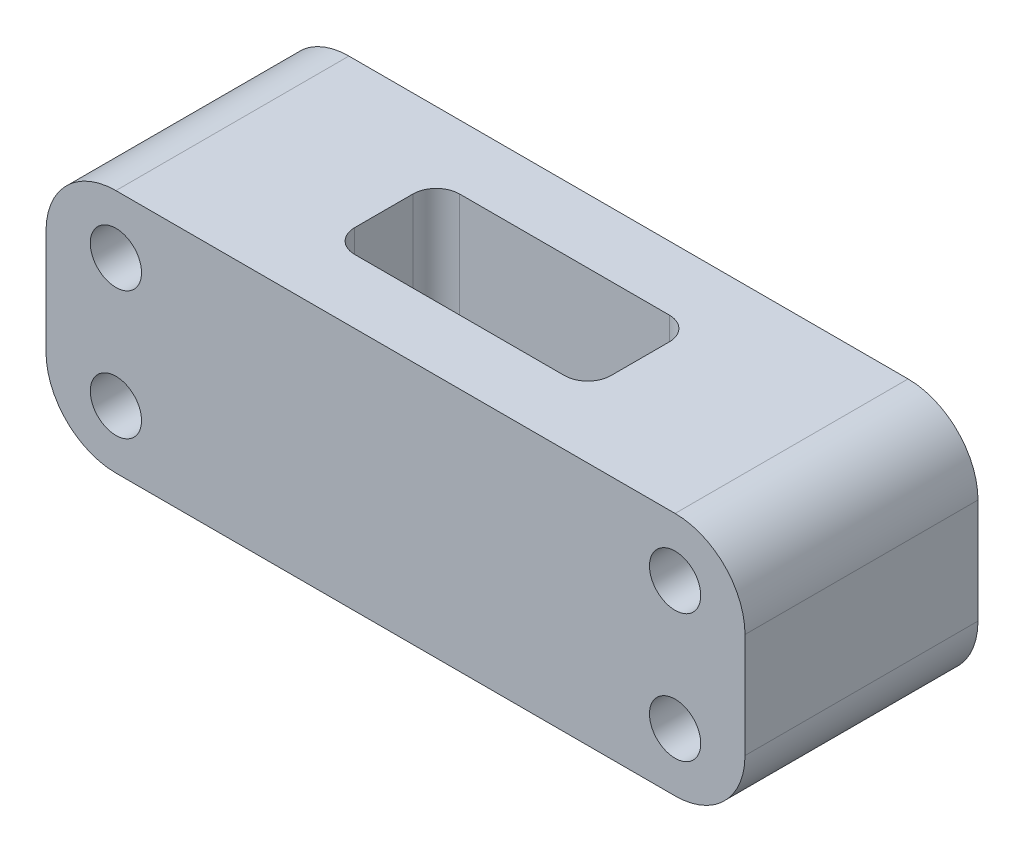
from build123d import *

# Parameters (mm, degrees)
BOSS_EXTRUDE1_DEPTH      = 10
BOSS_EXTRUDE1_DEPTH_BACK = 10
SKETCH1_W                = 60
SKETCH1_H                = 21
FILLET1_R                = 6
SKETCH2_R                = 2.2
CUT_EXTRUDE1_DEPTH       = 38.553295461
CUT_EXTRUDE2_DEPTH       = 38.960505792


with BuildPart() as part:
    # Sketch1 → Boss-Extrude1 (new, two sides: drawn at the far end of the back side and taken through both)
    with BuildSketch(Plane.XY.offset(-BOSS_EXTRUDE1_DEPTH_BACK)):
        Rectangle(SKETCH1_W, SKETCH1_H)
    extrude(amount=BOSS_EXTRUDE1_DEPTH + BOSS_EXTRUDE1_DEPTH_BACK)

    # Fillet1
    fillet1_edges = [part.edges().sort_by_distance(p)[0] for p in [
        (30, -10.5, 0),
        (30, 10.5, 0),
        (-30, -10.5, 0),
        (-30, 10.5, 0),
    ]]
    fillet(fillet1_edges, radius=FILLET1_R)

    # Sketch2 → Cut-Extrude1 (cut, through all)
    with BuildSketch(Plane.XY.offset(10)):
        with Locations((-24, 5.5)):
            Circle(SKETCH2_R)
        with Locations((24, 5.5)):
            Circle(SKETCH2_R)
        with Locations((24, -5.5)):
            Circle(SKETCH2_R)
        with Locations((-24, -5.5)):
            Circle(SKETCH2_R)
    extrude(amount=-CUT_EXTRUDE1_DEPTH, mode=Mode.SUBTRACT)

    # Sketch3 → Cut-Extrude2 (cut, through all)
    with BuildSketch(Plane(origin=(0, 10.5, 0), x_dir=(1, 0, 0), z_dir=(0, 1, 0))):
        with BuildLine():
            Line((9, -4.5), (-9, -4.5))
            ThreePointArc((-9, -4.5), (-10.414213562, -3.914213562), (-11, -2.5))
            Line((-11, -2.5), (-11, 2.5))
            ThreePointArc((-11, 2.5), (-10.414213562, 3.914213562), (-9, 4.5))
            Line((-9, 4.5), (9, 4.5))
            ThreePointArc((9, 4.5), (10.414213562, 3.914213562), (11, 2.5))
            Line((11, 2.5), (11, -2.5))
            ThreePointArc((11, -2.5), (10.414213562, -3.914213562), (9, -4.5))
        make_face()
    extrude(amount=-CUT_EXTRUDE2_DEPTH, mode=Mode.SUBTRACT)


solid = part.part
